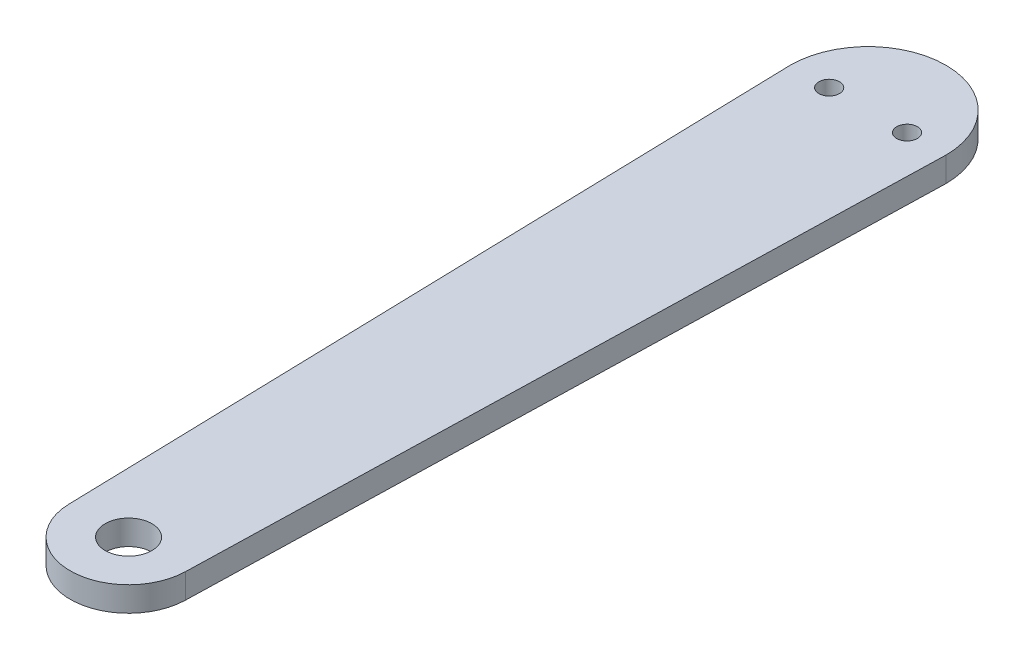
from build123d import *

# Parameters (mm, degrees)
SKETCH1_R            = 6
BOSS_EXTRUDE1_DEPTH  = 6.35
M5_CLEARANCE_HOLE1_D = 5.3


with BuildPart() as part:
    # Sketch1 → Boss-Extrude1 (new body)
    with BuildSketch(Plane(origin=(0, 0, 0), x_dir=(1, 0, 0), z_dir=(0, 1, 0))):
        with BuildLine():
            Line((-20, 0), (-14.99481954, -190.394191531))
            ThreePointArc((-14.99481954, -190.394191531), (0, -205), (14.99481954, -190.394191531))
            Line((14.99481954, -190.394191531), (20, 0))
            ThreePointArc((20, 0), (0, 20), (-20, 0))
        make_face()
        with Locations((0, -190)):
            Circle(SKETCH1_R, mode=Mode.SUBTRACT)
    extrude(amount=BOSS_EXTRUDE1_DEPTH)

    # M5 Clearance Hole1 (through all)
    with Locations(Plane(origin=(0, 6.35, 0), x_dir=(1, 0, 0), z_dir=(0, 1, 0))):
        with Locations((-10, 0), (10, 0)):
            Hole(M5_CLEARANCE_HOLE1_D / 2)


solid = part.part
